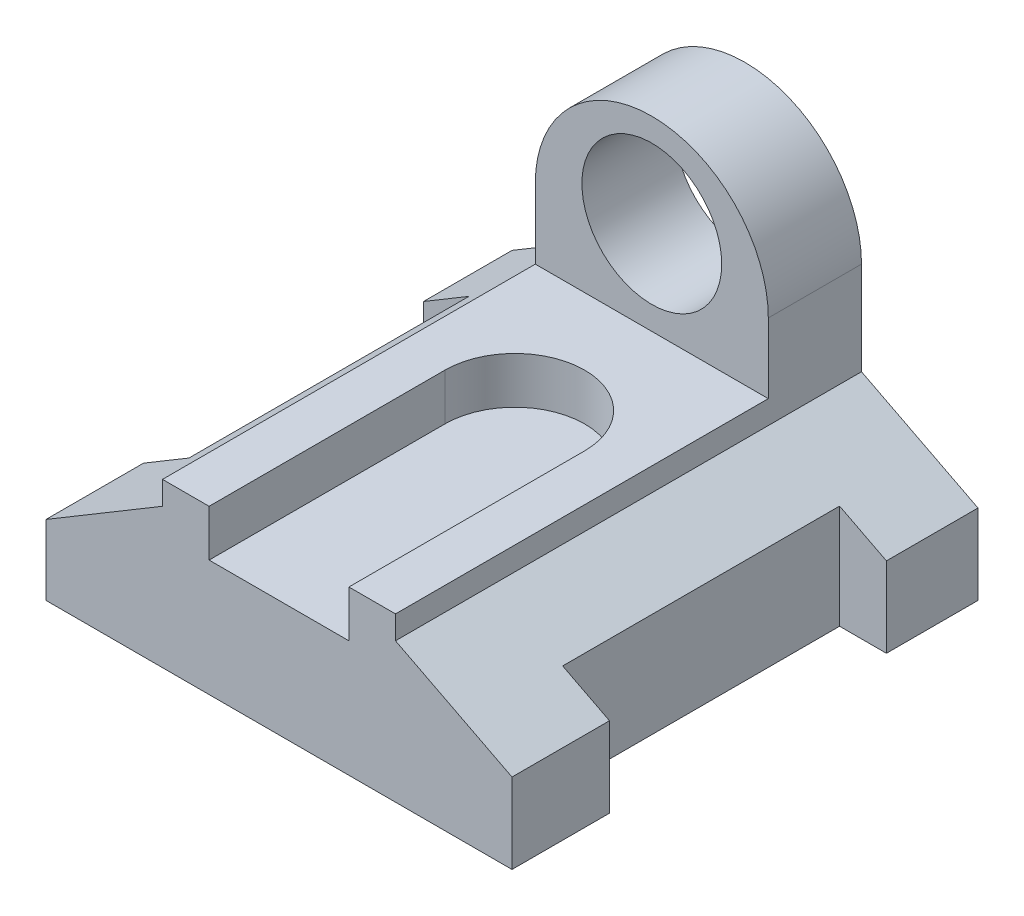
from build123d import *

# Parameters (mm, degrees)
SKETCH1_W               = 100
SKETCH1_H               = 30
BOSS_EXTRUDE1_DEPTH     = 100
SKETCH2_W               = 50
SKETCH2_H               = 5
BOSS_EXTRUDE2_DEPTH     = 100
BOSS_EXTRUDE3_DEPTH     = 20
SKETCH4_R               = 15
CUT_EXTRUDE2_DEPTH      = 20
SKETCH5_W               = 9.754337327
SKETCH5_H               = 60.08086333
CUT_EXTRUDE3_DEPTH      = 55.43877551
CUT_EXTRUDE3_DEPTH_BACK = 21.56122449
SKETCH6_W               = 10.053487374
SKETCH6_H               = 59.424714791
CUT_EXTRUDE4_DEPTH      = 46
CUT_EXTRUDE4_DEPTH_BACK = 31
CUT_EXTRUDE5_DEPTH      = 10
CUT_EXTRUDE9_DEPTH      = 130
CUT_EXTRUDE11_DEPTH     = 130


with BuildPart() as part:
    # Sketch1 → Boss-Extrude1 (new body)
    with BuildSketch(Plane.XY):
        with Locations((13.775510204, -5.56122449)):
            Rectangle(SKETCH1_W, SKETCH1_H)
    extrude(amount=BOSS_EXTRUDE1_DEPTH)

    # Sketch2 → Boss-Extrude2 (add)
    with BuildSketch(Plane.XY):
        with Locations((13.775510204, 11.93877551)):
            Rectangle(SKETCH2_W, SKETCH2_H)
    extrude(amount=BOSS_EXTRUDE2_DEPTH)

    # Sketch3 → Boss-Extrude3 (add)
    with BuildSketch(Plane.XY):
        with BuildLine():
            Line((-11.224489796, 14.43877551), (38.775510204, 14.43877551))
            Line((38.775510204, 14.43877551), (38.775510204, 29.43877551))
            ThreePointArc((38.775510204, 29.43877551), (13.775510204, 54.43877551), (-11.224489796, 29.43877551))
            Line((-11.224489796, 29.43877551), (-11.224489796, 14.43877551))
        make_face()
    extrude(amount=BOSS_EXTRUDE3_DEPTH)

    # Sketch4 → Cut-Extrude2 (cut)
    with BuildSketch(Plane.XY.offset(20)):
        with Locations((13.775510204, 34.43877551)):
            Circle(SKETCH4_R)
    extrude(amount=-CUT_EXTRUDE2_DEPTH, mode=Mode.SUBTRACT)

    # Sketch5 → Cut-Extrude3 (cut, two sides)
    with BuildSketch(Plane(origin=(0, 0, 0), x_dir=(1, 0, 0), z_dir=(0, 1, 0))) as cut_extrude3_sk:
        with Locations((-31.347321132, -49.035804096)):
            Rectangle(SKETCH5_W, SKETCH5_H)
    extrude(amount=CUT_EXTRUDE3_DEPTH, mode=Mode.SUBTRACT)
    extrude(cut_extrude3_sk.sketch, amount=-CUT_EXTRUDE3_DEPTH_BACK, mode=Mode.SUBTRACT)

    # Sketch6 → Cut-Extrude4 (cut, two sides)
    with BuildSketch(Plane(origin=(0, 9.43877551, 0), x_dir=(1, 0, 0), z_dir=(0, 1, 0))) as cut_extrude4_sk:
        with Locations((58.748766517, -49.363878365)):
            Rectangle(SKETCH6_W, SKETCH6_H)
    extrude(amount=CUT_EXTRUDE4_DEPTH, mode=Mode.SUBTRACT)
    extrude(cut_extrude4_sk.sketch, amount=-CUT_EXTRUDE4_DEPTH_BACK, mode=Mode.SUBTRACT)

    # Sketch7 → Cut-Extrude5 (cut)
    with BuildSketch(Plane(origin=(0, 14.43877551, 0), x_dir=(1, 0, 0), z_dir=(0, 1, 0))):
        with BuildLine():
            Line((-1.224489796, -90), (-1.224489796, -100))
            Line((-1.224489796, -100), (28.775510204, -100))
            Line((28.775510204, -100), (28.775510204, -90))
            Line((28.775510204, -90), (28.775510204, -49.395873988))
            ThreePointArc((28.775510204, -49.395873988), (13.775510204, -34.395873988), (-1.224489796, -49.395873988))
            Line((-1.224489796, -49.395873988), (-1.224489796, -90))
        make_face()
    extrude(amount=-CUT_EXTRUDE5_DEPTH, mode=Mode.SUBTRACT)

    # Sketch8 → Cut-Extrude9 (cut)
    with BuildSketch(Plane.XY.offset(100)):
        Polygon((63.775510204, 3.25154294), (63.775510204, 9.43877551), (51.275510204, 9.43877551), align=None)
        Polygon((-36.224489796, 9.43877551), (-23.724489796, 9.43877551), (-36.224489796, 3.25154294), align=None)
    extrude(amount=-CUT_EXTRUDE9_DEPTH, mode=Mode.SUBTRACT)

    # Sketch9 → Cut-Extrude11 (cut)
    with BuildSketch(Plane.XY.offset(100)):
        Polygon((-11.224489796, 9.43877551), (-36.224489796, -5.508285905), (-36.224489796, 9.273925271), (-21.818059328, 14.371872445), align=None)
        Polygon((38.775510204, 9.43877551), (67.925947804, 9.43877551), (67.925947804, -5.508285905), align=None)
    extrude(amount=-CUT_EXTRUDE11_DEPTH, mode=Mode.SUBTRACT)


solid = part.part
